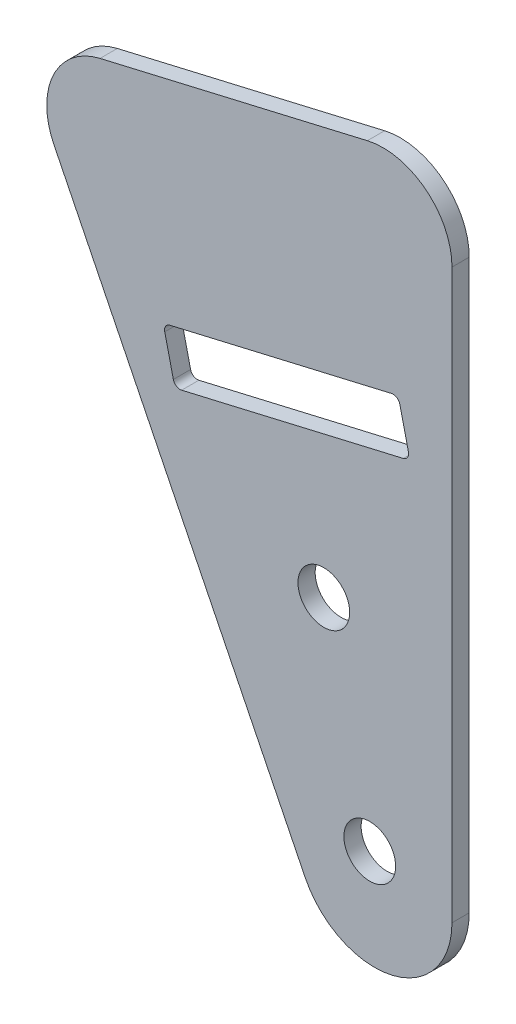
from build123d import *

# Parameters (mm, degrees)
SKETCH1_R           = 4.7625
BOSS_EXTRUDE1_DEPTH = 3.175
FILLET1_R           = 1.27


with BuildPart() as part:
    # Sketch1 → Boss-Extrude1 (new body)
    with BuildSketch(Plane.XY):
        with BuildLine():
            Line((-85.640420597, 747.8061934), (-39.363598028, 654.043532069))
            ThreePointArc((-39.363598028, 654.043532069), (-23.3459714, 646.472574481), (-12.333293773, 660.350783769))
            Line((-12.333293773, 660.350783769), (-12.333293773, 764.911679744))
            ThreePointArc((-12.333293773, 764.911679744), (-17.139019283, 774.860068069), (-27.919188304, 777.279444811))
            Line((-27.919188304, 777.279444811), (-77.137872176, 765.794756196))
            ThreePointArc((-77.137872176, 765.794756196), (-85.733975533, 758.854119696), (-85.640420597, 747.8061934))
        make_face()
        with Locations((-35.934636682, 700.422451369)):
            Circle(SKETCH1_R, mode=Mode.SUBTRACT)
        with Locations((-27.475367191, 664.169477971)):
            Circle(SKETCH1_R, mode=Mode.SUBTRACT)
        Polygon((-63.350014613, 720.107666072), (-20.062836878, 730.208296933), (-22.227257777, 739.484120734), (-65.514435511, 729.383489872), align=None, mode=Mode.SUBTRACT)
    extrude(amount=BOSS_EXTRUDE1_DEPTH)

    # Fillet1
    fillet1_edges = [part.edges().sort_by_distance(p)[0] for p in [
        (-20.062836878, 730.208296933, 1.5875),
        (-22.227257777, 739.484120734, 1.5875),
        (-65.514435511, 729.383489872, 1.5875),
        (-63.350014613, 720.107666072, 1.5875),
    ]]
    fillet(fillet1_edges, radius=FILLET1_R)


solid = part.part
